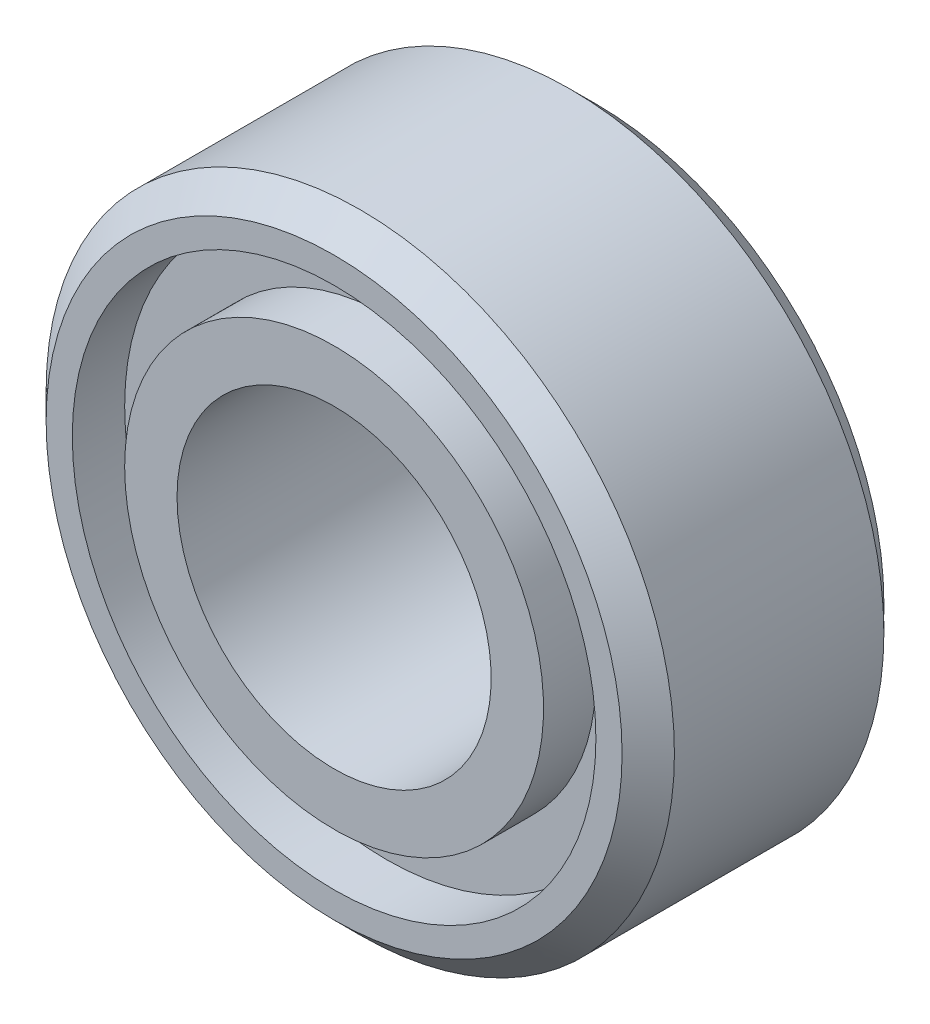
from build123d import *


with BuildPart() as part:
    # Sketch1 → Revolve1 (revolve)
    with BuildSketch(Plane.XZ):
        Polygon((3, -0.25), (2.75, 0), (2.5, 0), (2.5, -0.5), (2, -0.5), (2, 0), (1.5, 0), (1.5, -2.5), (2, -2.5), (2, -2), (2.5, -2), (2.5, -2.5), (2.75, -2.5), (3, -2.25), align=None)
    revolve(axis=Axis((0, 0, 2.5), (0, 0, -1)))


solid = part.part
